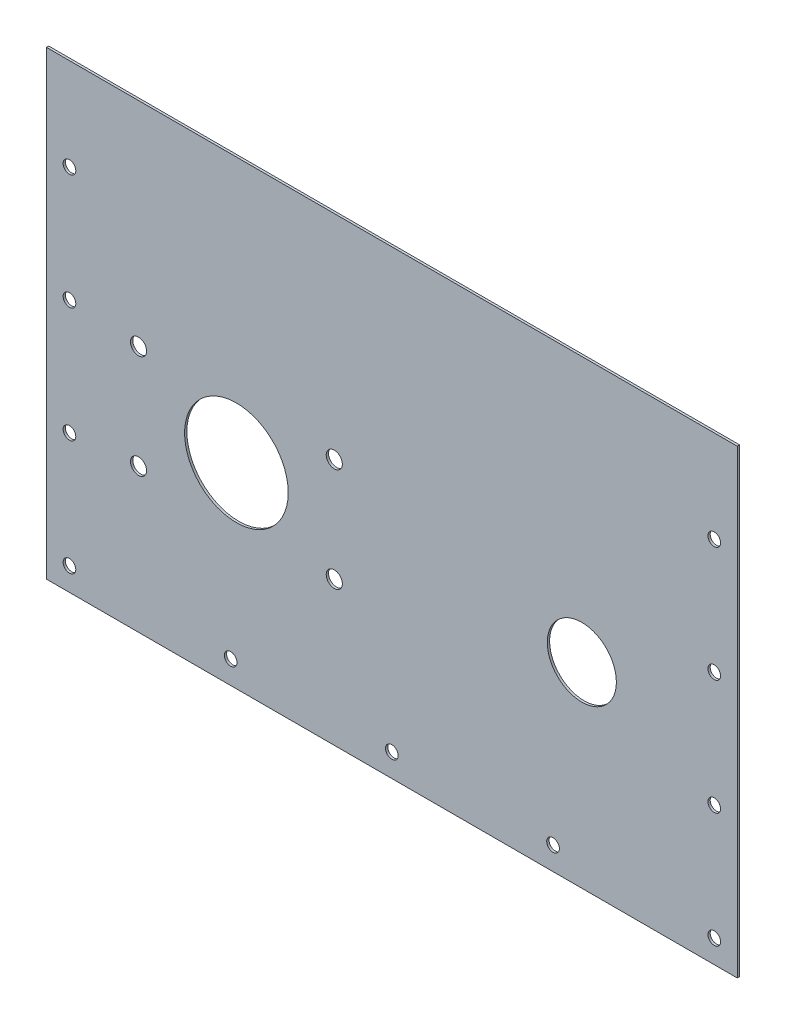
from build123d import *

# Parameters (mm, degrees)
SKETCH_1_W          = 300
SKETCH_1_H          = 220
EXTRUDE_1_DEPTH     = 1
HOLE_WIZARD_M5_1_D  = 5.5
SKETCH_4_W          = 300
SKETCH_4_H          = 20
CUT_EXTRUDE_1_DEPTH = 10
SKETCH_5_R          = 22.5
SKETCH_5_R_2        = 15
SKETCH_5_R_3        = 3.5
CUT_EXTRUDE_2_DEPTH = 10


with BuildPart() as part:
    # 스케치1 → 보스-돌출1 (new body)
    with BuildSketch(Plane.XY):
        Rectangle(SKETCH_1_W, SKETCH_1_H)
    extrude(amount=EXTRUDE_1_DEPTH)

    # M5 여유 구멍1 (through all)
    with Locations(Plane(origin=(0, 0, 0), x_dir=(-1, 0, 0), z_dir=(0, 0, -1))):
        with Locations((-140, 100), (-70, 100), (70, 100), (0, 100), (140, 100), (140, 50), (140, -50), (140, 0), (140, -100), (-140, 50), (-140, -50), (-140, 0), (-140, -100), (-70, -100), (70, -100), (0, -100)):
            Hole(HOLE_WIZARD_M5_1_D / 2)

    # 스케치4 → 컷-돌출1 (cut)
    with BuildSketch(Plane.XY.offset(1)):
        with Locations((0, 100)):
            Rectangle(SKETCH_4_W, SKETCH_4_H)
    extrude(amount=-CUT_EXTRUDE_1_DEPTH, mode=Mode.SUBTRACT)

    # 스케치5 → 컷-돌출2 (cut)
    with BuildSketch(Plane.XY.offset(1)):
        with Locations((-67.5, -25)):
            Circle(SKETCH_5_R)
        with Locations((82.5, -25)):
            Circle(SKETCH_5_R_2)
        with Locations((-25, -47.5)):
            Circle(SKETCH_5_R_3)
        with Locations((-25, -2.5)):
            Circle(SKETCH_5_R_3)
        with Locations((-110, -47.5)):
            Circle(SKETCH_5_R_3)
        with Locations((-110, -2.5)):
            Circle(SKETCH_5_R_3)
    extrude(amount=-CUT_EXTRUDE_2_DEPTH, mode=Mode.SUBTRACT)


solid = part.part
